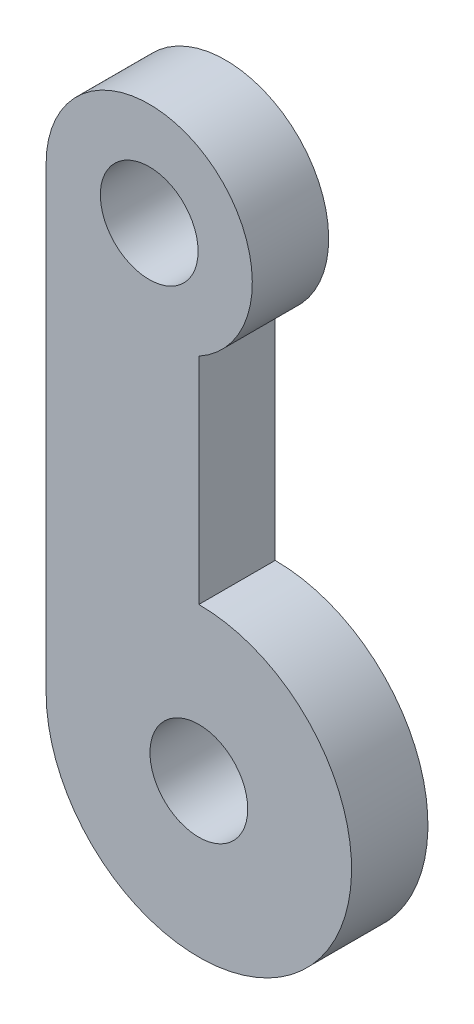
from build123d import *

# Parameters (mm, degrees)
SKETCH1_R           = 5
SKETCH1_R_2         = 1.6
SKETCH1_R_3         = 3.375
BOSS_EXTRUDE1_DEPTH = 2.5


with BuildPart() as part:
    # Sketch1 → Boss-Extrude1 (new body)
    with BuildSketch(Plane.XY):
        with Locations((1.625, -15)):
            Circle(SKETCH1_R)
        with Locations((1.625, -15)):
            Circle(SKETCH1_R_2, mode=Mode.SUBTRACT)
        with BuildLine():
            Line((-3.375, 0), (-3.375, -15))
            ThreePointArc((-3.375, -15), (-1.910533906, -11.464466094), (1.625, -10))
            Line((1.625, -10), (1.625, -2.958039892))
            ThreePointArc((1.625, -2.958039892), (-1.718465886, -2.90473751), (-3.375, 0))
        make_face()
        Circle(SKETCH1_R_3)
        Circle(SKETCH1_R_2, mode=Mode.SUBTRACT)
    extrude(amount=BOSS_EXTRUDE1_DEPTH)


solid = part.part
